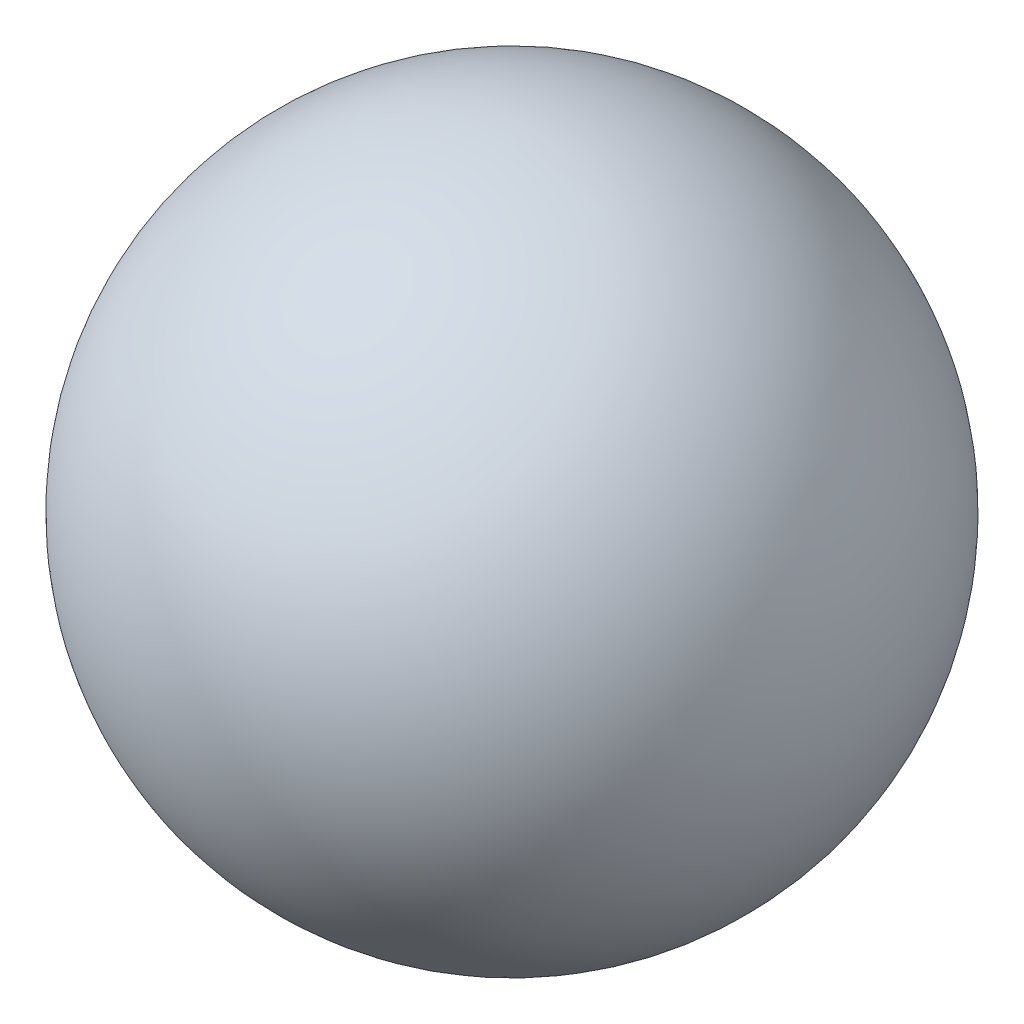
from build123d import *


with BuildPart() as part:
    # Sketch1 → Revolve1 (revolve)
    with BuildSketch(Plane(origin=(0, 0, 0), x_dir=(1, 0, 0), z_dir=(0, 1, 0))):
        with BuildLine():
            Line((0, 76.2), (0, -76.2))
            ThreePointArc((0, -76.2), (76.2, 0), (0, 76.2))
        make_face()
    revolve(axis=Axis((0, 0, -76.2), (0, 0, 1)))


solid = part.part
